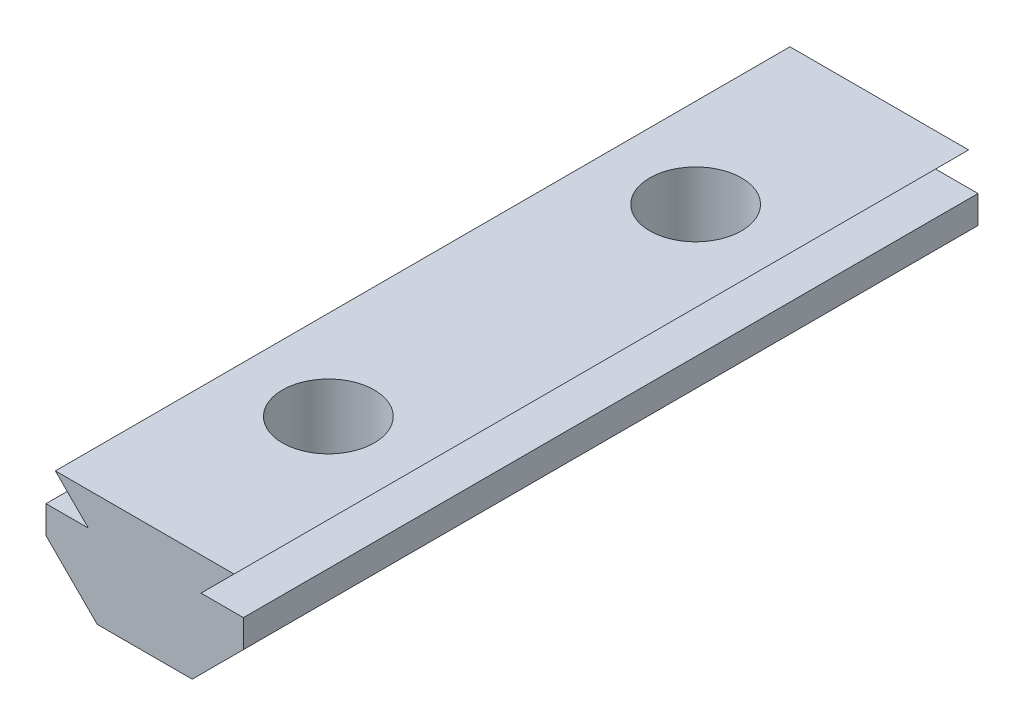
from build123d import *

# Parameters (mm, degrees)
BOSS_EXTRUDE1_DEPTH = 40
SKETCH2_R           = 2.5
CUT_EXTRUDE1_DEPTH  = 7.1


with BuildPart() as part:
    # Sketch1 → Boss-Extrude1 (new body)
    with BuildSketch(Plane.XY):
        Polygon((-2.585653528, 0), (2.585653528, 0), (5.375, 2.789346472), (5.375, 4.3), (3.065, 4.3), (4.865, 6.1), (-4.865, 6.1), (-3.065, 4.3), (-5.375, 4.3), (-5.375, 2.789346472), align=None)
    extrude(amount=BOSS_EXTRUDE1_DEPTH)

    # Sketch2 → Cut-Extrude1 (cut, through all)
    with BuildSketch(Plane(origin=(0, 6.1, 0), x_dir=(1, 0, 0), z_dir=(0, 1, 0))):
        with Locations((0, -30)):
            Circle(SKETCH2_R)
        with Locations((0, -10)):
            Circle(SKETCH2_R)
    extrude(amount=-CUT_EXTRUDE1_DEPTH, mode=Mode.SUBTRACT)


solid = part.part
